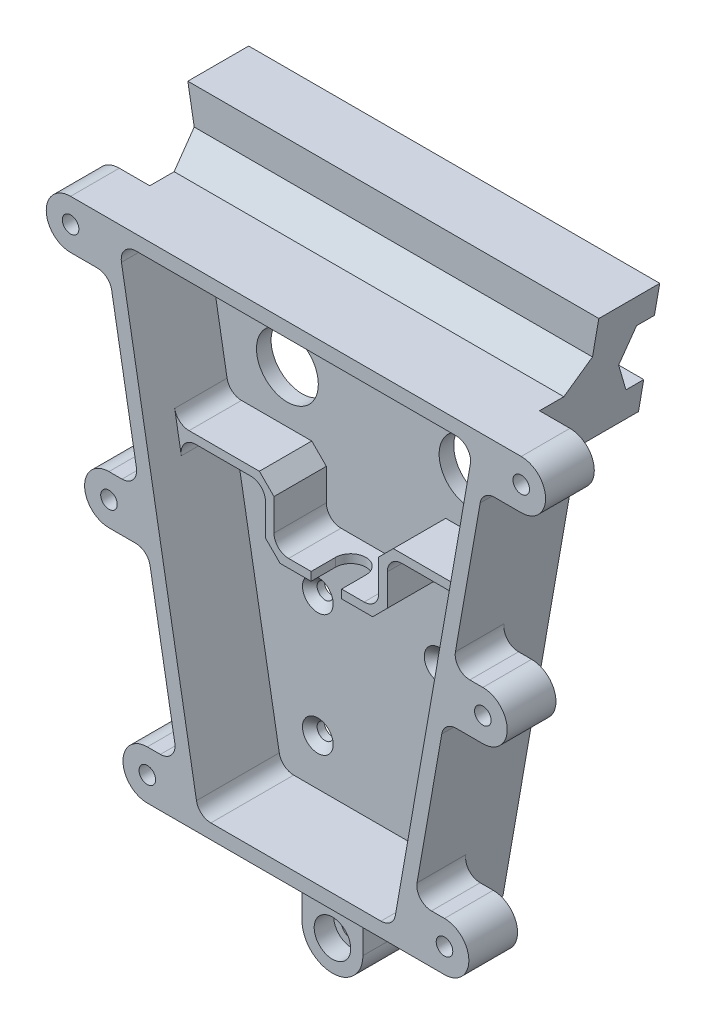
from build123d import *

# Parameters (mm, degrees)
MAIN_BOBY_DEPTH                                 = 40
WALL_THICKNESS_T                                = -6
RIB_DEPTH                                       = 21.5
TOP_BOSS_DEPTH                                  = 25
TABS_DEPTH                                      = 20
V_SLOT_DEPTH                                    = 103.5
V_SLOT_DEPTH_BACK                               = 103.5
U_CUTOUT_REACH                                  = 127
BOTTOM_BOSS_DEPTH                               = 25
LARGE_HOLES_REACH                               = 33
SKETCH8_R                                       = 12.7
CSK_FOR_M6_FLAT_HEAD_MACHINE_SCREW1_D           = 6.6
CSK_FOR_M6_FLAT_HEAD_MACHINE_SCREW1_CSINK_D     = 12.6
CSK_FOR_M6_FLAT_HEAD_MACHINE_SCREW1_CSINK_ANGLE = 90
CBORE_FOR_M8_SHCS1_D                            = 9
CBORE_FOR_M8_SHCS1_DEPTH                        = 25
CBORE_FOR_M8_SHCS1_CBORE_D                      = 15
CBORE_FOR_M8_SHCS1_CBORE_DEPTH                  = 8
M6X1_0_TAPPED_HOLE1_D                           = 5
M6X1_0_TAPPED_HOLE1_DEPTH                       = 17
M6X1_0_TAPPED_HOLE1_TIP                         = 1.502151548
M8X1_25_TAPPED_HOLE2_D                          = 6.8
M8X1_25_TAPPED_HOLE2_DEPTH                      = 20
FILLET1_R                                       = 6
CHAMFER1_SIZE                                   = 10
CHAMFER2_SIZE                                   = 6


with BuildPart() as part:
    # Sketch1 → Main Boby (new body)
    with BuildSketch(Plane.XY):
        Polygon((80, 200), (-80, 200), (-45, 0), (45, 0), align=None)
    extrude(amount=MAIN_BOBY_DEPTH)

    # Wall Thickness
    wall_thickness_openings = [part.faces().sort_by_distance(p)[0] for p in [
        (0, 100, 40),
    ]]
    offset(amount=WALL_THICKNESS_T, openings=wall_thickness_openings, kind=Kind.INTERSECTION)

    # Sketch2 → Rib (add)
    with BuildSketch(Plane.XY.offset(6)):
        Polygon((-66.875, 125), (-25, 125), (-25, 100), (25, 100), (25, 125), (66.875, 125), (66.875, 128.5), (21.5, 128.5), (21.5, 103.5), (-21.5, 103.5), (-21.5, 128.5), (-66.875, 128.5), align=None)
    extrude(amount=RIB_DEPTH)

    # Sketch3 → Top Boss (add)
    with BuildSketch(Plane(origin=(0, 0, 0), x_dir=(-1, 0, 0), z_dir=(0, 0, -1))):
        Polygon((-84.375, 225), (84.375, 225), (75.625, 175), (-75.625, 175), align=None)
    extrude(amount=TOP_BOSS_DEPTH)

    # Sketch4 → Tabs (add)
    with BuildSketch(Plane.XY.offset(40)):
        with BuildLine():
            Line((80, 200), (92.5, 200))
            ThreePointArc((92.5, 200), (102.5, 190), (92.5, 180))
            Line((92.5, 180), (76.5, 180))
            Line((76.5, 180), (80, 200))
        make_face()
        with BuildLine():
            Line((64.25, 110), (76.75, 110))
            ThreePointArc((76.75, 110), (86.75, 100), (76.75, 90))
            Line((76.75, 90), (60.75, 90))
            Line((60.75, 90), (64.25, 110))
        make_face()
        with BuildLine():
            Line((48.5, 20), (61, 20))
            ThreePointArc((61, 20), (71, 10), (61, 0))
            Line((61, 0), (45, 0))
            Line((45, 0), (48.5, 20))
        make_face()
    tabs = extrude(amount=-TABS_DEPTH)

    # Mirror1: Tabs across plane
    add(tabs.mirror(Plane(origin=(0, 0, 0), x_dir=(0, 0, 1), z_dir=(1, 0, 0))))

    # Sketch5 → V Slot (cut, two sides)
    with BuildSketch(Plane(origin=(0, 0, 0), x_dir=(0, 0, -1), z_dir=(1, 0, 0))) as v_slot_sk:
        Polygon((25, 212.5), (17.67766953, 212.5), (12.5, 200), (17.67766953, 187.5), (25, 187.5), align=None)
    extrude(amount=V_SLOT_DEPTH, mode=Mode.SUBTRACT)
    extrude(v_slot_sk.sketch, amount=-V_SLOT_DEPTH_BACK, mode=Mode.SUBTRACT)

    # Sketch6 → U Cutout (cut, up to next)
    with BuildSketch(Plane.XZ.offset(-100), mode=Mode.PRIVATE) as u_cutout_sk1:
        with BuildLine():
            Line((-6.25, 27.5), (-6.25, 17.5))
            ThreePointArc((-6.25, 17.5), (0, 11.25), (6.25, 17.5))
            Line((6.25, 17.5), (6.25, 27.5))
            Line((6.25, 27.5), (-6.25, 27.5))
        make_face()
    u_cutout_tool1 = extrude(u_cutout_sk1.sketch, amount=-U_CUTOUT_REACH, mode=Mode.PRIVATE) & part.part
    add(u_cutout_tool1.solids().sort_by_distance((0, 100, 19.980369))[0], mode=Mode.SUBTRACT)

    # Sketch7 → Bottom Boss (add)
    with BuildSketch(Plane(origin=(0, 0, 0), x_dir=(-1, 0, 0), z_dir=(0, 0, -1))):
        with BuildLine():
            Line((-12.5, 0), (-12.5, -25))
            ThreePointArc((-12.5, -25), (0, -37.5), (12.5, -25))
            Line((12.5, -25), (12.5, 0))
            Line((12.5, 0), (-12.5, 0))
        make_face()
    extrude(amount=-BOTTOM_BOSS_DEPTH)

    # Sketch8 → Large Holes (cut, up to next)
    with BuildSketch(Plane.XY.offset(6), mode=Mode.PRIVATE) as large_holes_sk1:
        with Locations((-37.5, 150)):
            Circle(SKETCH8_R)
    large_holes_tool1 = extrude(large_holes_sk1.sketch, amount=-LARGE_HOLES_REACH, mode=Mode.PRIVATE) & part.part
    add(large_holes_tool1.solids().sort_by_distance((-37.5, 150, 6))[0], mode=Mode.SUBTRACT)
    # Sketch8 → Large Holes (cut, up to next)
    with BuildSketch(Plane.XY.offset(6), mode=Mode.PRIVATE) as large_holes_sk2:
        with Locations((37.5, 150)):
            Circle(SKETCH8_R)
    large_holes_tool2 = extrude(large_holes_sk2.sketch, amount=-LARGE_HOLES_REACH, mode=Mode.PRIVATE) & part.part
    add(large_holes_tool2.solids().sort_by_distance((37.5, 150, 6))[0], mode=Mode.SUBTRACT)

    # CSK for M6 Flat Head Machine Screw1 (through all)
    with Locations(Plane.XY.offset(6)):
        with Locations((-25, 75), (25, 75), (25, 25), (-25, 25)):
            CounterSinkHole(CSK_FOR_M6_FLAT_HEAD_MACHINE_SCREW1_D / 2, CSK_FOR_M6_FLAT_HEAD_MACHINE_SCREW1_CSINK_D / 2, counter_sink_angle=CSK_FOR_M6_FLAT_HEAD_MACHINE_SCREW1_CSINK_ANGLE)

    # CBORE for M8 SHCS1
    with Locations(Plane.XY.offset(25)):
        with Locations((0, -25)):
            CounterBoreHole(CBORE_FOR_M8_SHCS1_D / 2, CBORE_FOR_M8_SHCS1_CBORE_D / 2, CBORE_FOR_M8_SHCS1_CBORE_DEPTH, depth=CBORE_FOR_M8_SHCS1_DEPTH)

    # M6x1.0 Tapped Hole1
    with Locations(Plane(origin=(0, 0, -25), x_dir=(-1, 0, 0), z_dir=(0, 0, -1))):
        with Locations((-62.5, 218.75), (0, 218.75), (62.5, 218.75)):
            Hole(M6X1_0_TAPPED_HOLE1_D / 2, depth=M6X1_0_TAPPED_HOLE1_DEPTH)
            with Locations((0, 0, -(M6X1_0_TAPPED_HOLE1_DEPTH + M6X1_0_TAPPED_HOLE1_TIP / 2))):  # 118° drill point
                Cone(0, M6X1_0_TAPPED_HOLE1_D / 2, M6X1_0_TAPPED_HOLE1_TIP, mode=Mode.SUBTRACT)

    # M8x1.25 Tapped Hole2
    with Locations(Plane.XY.offset(40)):
        with Locations((-92.5, 190), (92.5, 190), (76.75, 100), (-76.75, 100), (-61, 10), (61, 10)):
            Hole(M8X1_25_TAPPED_HOLE2_D / 2, depth=M8X1_25_TAPPED_HOLE2_DEPTH)

    # Fillet1
    fillet1_edges = [part.edges().sort_by_distance(p)[0] for p in [
        (48.5, 20, 30),
        (-76.5, 180, 30),
        (-64.25, 110, 30),
        (-60.75, 90, 30),
        (-48.5, 20, 30),
        (39.958817849, 6, 23),
        (72.858817849, 194, 23),
        (-72.858817849, 194, 23),
        (-39.958817849, 6, 23),
        (12.5, 0, 12.5),
        (-12.5, 0, 12.5),
        (60.783817849, 125, 16.75),
        (-60.783817849, 125, 16.75),
        (25, 125, 16.75),
        (61.396317849, 128.5, 16.75),
        (21.5, 103.5, 16.75),
        (-21.5, 103.5, 16.75),
        (-61.396317849, 128.5, 16.75),
        (-25, 125, 16.75),
        (76.5, 180, 30),
        (60.75, 90, 30),
        (64.25, 110, 30),
    ]]
    fillet(fillet1_edges, radius=FILLET1_R)

    # Chamfer1
    chamfer1_edges = [part.edges().sort_by_distance(p)[0] for p in [
        (0, 200, 0),
    ]]
    chamfer(chamfer1_edges, length=CHAMFER1_SIZE)

    # Chamfer2
    chamfer2_edges = [part.edges().sort_by_distance(p)[0] for p in [
        (21.5, 128.5, 16.75),
        (-21.5, 128.5, 16.75),
        (-25, 100, 16.75),
        (25, 100, 16.75),
    ]]
    chamfer(chamfer2_edges, length=CHAMFER2_SIZE)


solid = part.part
